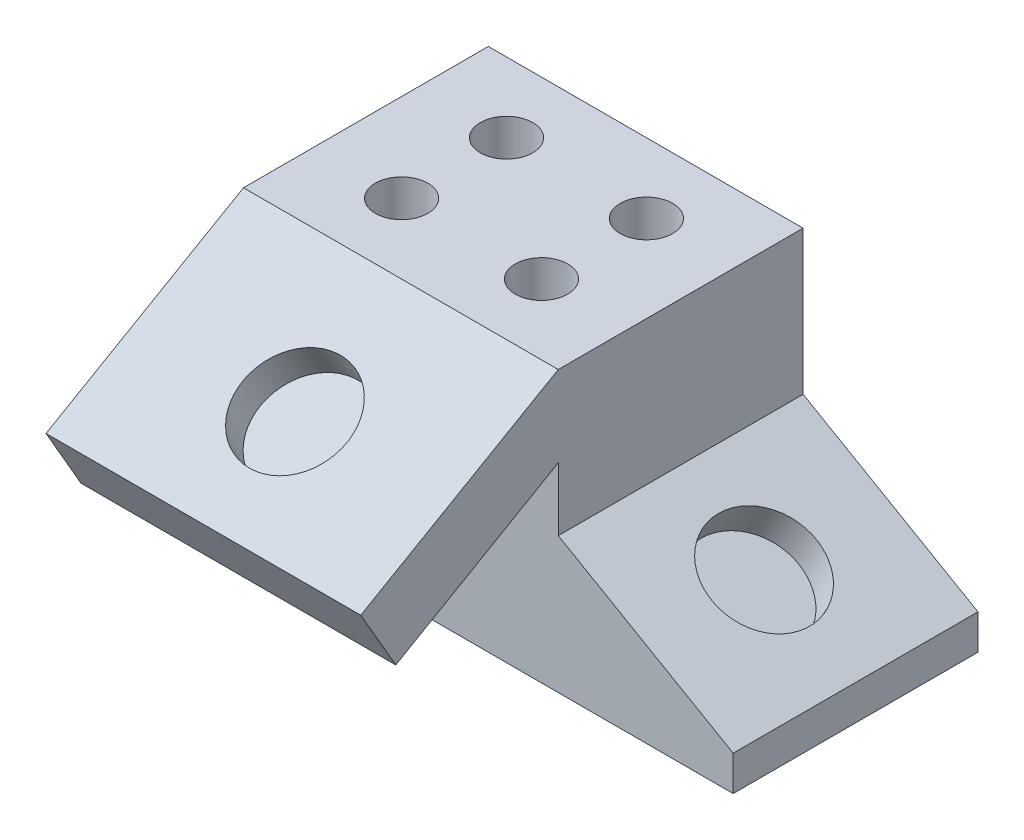
from build123d import *

# Parameters (mm, degrees)
BOSS_EXTRUDE1_DEPTH = 44.45
SKETCH2_R           = 4.7625
CUT_EXTRUDE1_DEPTH  = 12.7
SKETCH3_R           = 9.525
CUT_EXTRUDE2_DEPTH  = 6.35
BOSS_EXTRUDE2_DEPTH = 57.15
SKETCH5_R           = 9.525
CUT_EXTRUDE3_DEPTH  = 6.35


with BuildPart() as part:
    # Sketch1 → Boss-Extrude1 (new body)
    with BuildSketch(Plane.XY):
        Polygon((57.15, 0), (88.9, 0), (88.9, 6.35), (57.15, 24.680871047), (57.15, 50.8), (0, 50.8), (0, 0), align=None)
    extrude(amount=-BOSS_EXTRUDE1_DEPTH)

    # Sketch2 → Cut-Extrude1 (cut)
    with BuildSketch(Plane(origin=(0, 50.8, 0), x_dir=(1, 0, 0), z_dir=(0, 1, 0))):
        with Locations((16.002, 12.7)):
            Circle(SKETCH2_R)
        with Locations((41.402, 12.7)):
            Circle(SKETCH2_R)
        with Locations((41.402, 31.75)):
            Circle(SKETCH2_R)
        with Locations((16.002, 31.75)):
            Circle(SKETCH2_R)
    extrude(amount=-CUT_EXTRUDE1_DEPTH, mode=Mode.SUBTRACT)

    # Sketch3 → Cut-Extrude2 (cut)
    with BuildSketch(Plane(origin=(24.974630657, 43.257329198, 0), x_dir=(0.866025404, -0.5, 0), z_dir=(0.5, 0.866025404, 0))):
        with Locations((54.764658396, 22.098)):
            Circle(SKETCH3_R)
    extrude(amount=-CUT_EXTRUDE2_DEPTH, mode=Mode.SUBTRACT)

    # Sketch4 → Boss-Extrude2 (add)
    with BuildSketch(Plane(origin=(57.15, 0, 0), x_dir=(0, 0, -1), z_dir=(1, 0, 0))):
        Polygon((0, 50.8), (-35.855183767, 30.099), (-29.505183767, 19.100477372), (0, 36.135303163), align=None)
    extrude(amount=-BOSS_EXTRUDE2_DEPTH)

    # Sketch5 → Cut-Extrude3 (cut)
    with BuildSketch(Plane(origin=(0, 38.1, 21.997045256), x_dir=(1, 0, 0), z_dir=(0, 0.866025404, 0.5))):
        with Locations((28.702, 3.048)):
            Circle(SKETCH5_R)
    extrude(amount=-CUT_EXTRUDE3_DEPTH, mode=Mode.SUBTRACT)


solid = part.part
